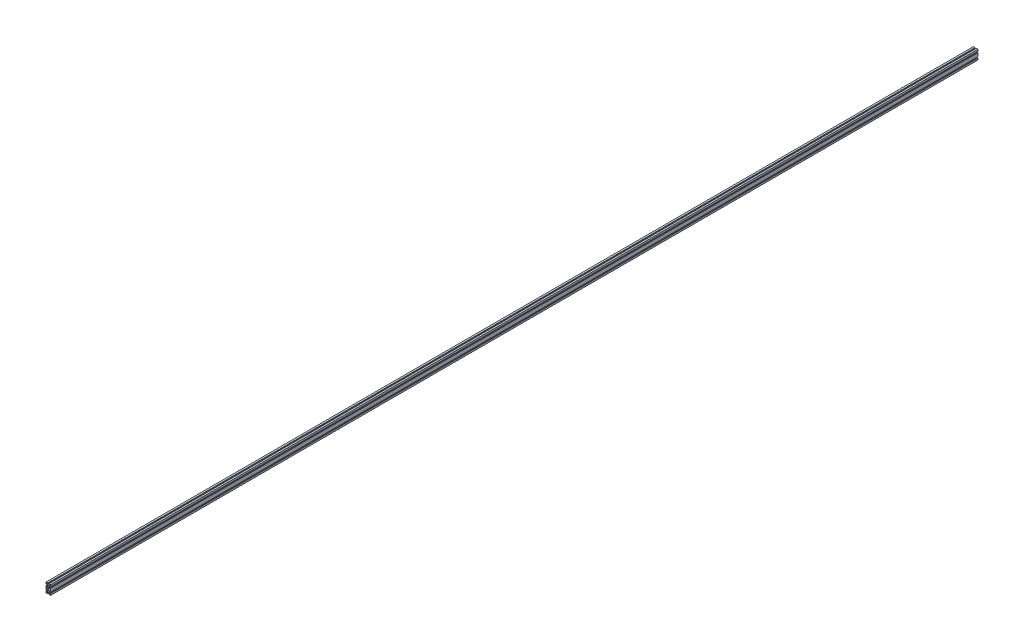
from build123d import *

# Parameters (mm, degrees)
SKETCH_B01_6_R   = 6.049999362
SKETCH_B01_6_R_2 = 6.050001038
SKETCH_B01_6_W   = 4.5
SKETCH_B01_6_H   = 4.5
EXTRUDE1_DEPTH   = 6000


with BuildPart() as part:
    # Sketch B01-6 → Extrude1 (new body)
    with BuildSketch(Plane.XY):
        Polygon((-13, -22.265685), (-11.634315, -22.265685), (-8.3, -18.931371213), (-8.3, -11.068628787), (-11.634315, -7.734315), (-13, -7.734315), (-13, -11), (-15, -11), (-15, 11), (-13, 11), (-13, 7.734315), (-11.634315, 7.734315), (-8.3, 11.068628787), (-8.3, 18.931371213), (-11.634315, 22.265685), (-13, 22.265685), (-13, 19), (-15, 19), (-15, 30), (-4, 30), (-4, 28), (-7.265685, 28), (-7.265685, 26.634315), (-3.931371213, 23.3), (3.931371213, 23.3), (7.265685, 26.634315), (7.265685, 28), (4, 28), (4, 30), (15, 30), (15, 19), (13, 19), (13, 22.265685), (11.634315, 22.265685), (8.3, 18.931371213), (8.3, 11.068628787), (11.634315, 7.734315), (13, 7.734315), (13, 11), (15, 11), (15, -11), (13, -11), (13, -7.734315), (11.634315, -7.734315), (8.3, -11.068628787), (8.3, -18.931371213), (11.634315, -22.265685), (13, -22.265685), (13, -19), (15, -19), (15, -30), (4, -30), (4, -28), (7.265685, -28), (7.265685, -26.634315), (3.931371213, -23.3), (-3.931371213, -23.3), (-7.265685, -26.634315), (-7.265685, -28), (-4, -28), (-4, -30), (-15, -30), (-15, -19), (-13, -19), align=None)
        with Locations((-2.09e-07, -14.999997135)):
            Circle(SKETCH_B01_6_R, mode=Mode.SUBTRACT)
        with Locations((-2.09e-07, 14.999997135)):
            Circle(SKETCH_B01_6_R_2, mode=Mode.SUBTRACT)
        with BuildLine():
            Line((-7.655281293, -9.603124178), (-7.202246191, -9.602996335))
            ThreePointArc((-7.202246191, -9.602996335), (-2.09e-07, -5.999999089), (7.202245773, -9.602996335))
            Line((7.202245773, -9.602996335), (7.655280874, -9.603124178))
            Line((7.655280874, -9.603124178), (11.258403758, -6))
            Line((11.258403758, -6), (12.994452, -6))
            Line((12.994452, -6), (12.994452, 6))
            Line((12.994452, 6), (11.258403758, 6))
            Line((11.258403758, 6), (7.655280874, 9.603124178))
            Line((7.655280874, 9.603124178), (7.202245773, 9.602996335))
            ThreePointArc((7.202245773, 9.602996335), (-2.09e-07, 5.999999089), (-7.202246191, 9.602996335))
            Line((-7.202246191, 9.602996335), (-7.655281293, 9.603124178))
            Line((-7.655281293, 9.603124178), (-11.258404176, 6))
            Line((-11.258404176, 6), (-12.994452419, 6))
            Line((-12.994452419, 6), (-12.994452419, -6))
            Line((-12.994452419, -6), (-11.258404176, -6))
            Line((-11.258404176, -6), (-7.655281293, -9.603124178))
        make_face(mode=Mode.SUBTRACT)
        with Locations((-11.25, -26.25)):
            Rectangle(SKETCH_B01_6_W, SKETCH_B01_6_H, mode=Mode.SUBTRACT)
        with Locations((-11.25, 26.25)):
            Rectangle(SKETCH_B01_6_W, SKETCH_B01_6_H, mode=Mode.SUBTRACT)
        with Locations((11.25, -26.25)):
            Rectangle(SKETCH_B01_6_W, SKETCH_B01_6_H, mode=Mode.SUBTRACT)
        with Locations((11.25, 26.25)):
            Rectangle(SKETCH_B01_6_W, SKETCH_B01_6_H, mode=Mode.SUBTRACT)
    extrude(amount=-EXTRUDE1_DEPTH)


solid = part.part
